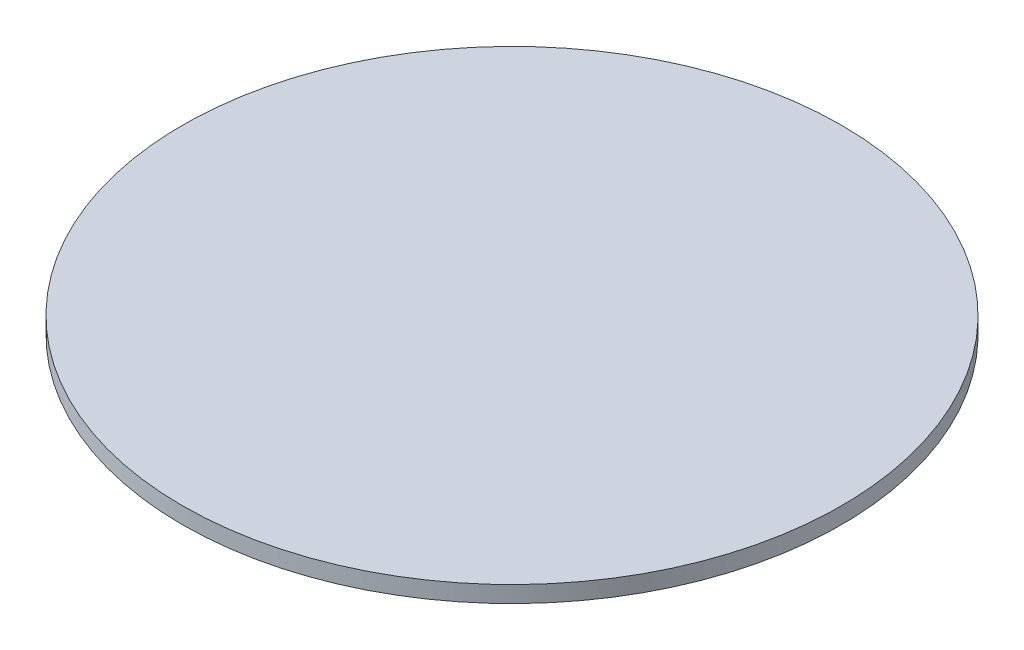
from build123d import *

# Parameters (mm, degrees)
SKETCH_1_R      = 25
EXTRUDE_1_DEPTH = 1.25


with BuildPart() as part:
    # 草图1 → 凸台-拉伸1 (new body)
    with BuildSketch(Plane(origin=(0, 0, 0), x_dir=(1, 0, 0), z_dir=(0, 1, 0))):
        with Locations(Location((0, 0, 0), (0, 0, 270))):  # turned: the seam where the file's is
            Circle(SKETCH_1_R)
    extrude(amount=EXTRUDE_1_DEPTH)


solid = part.part
